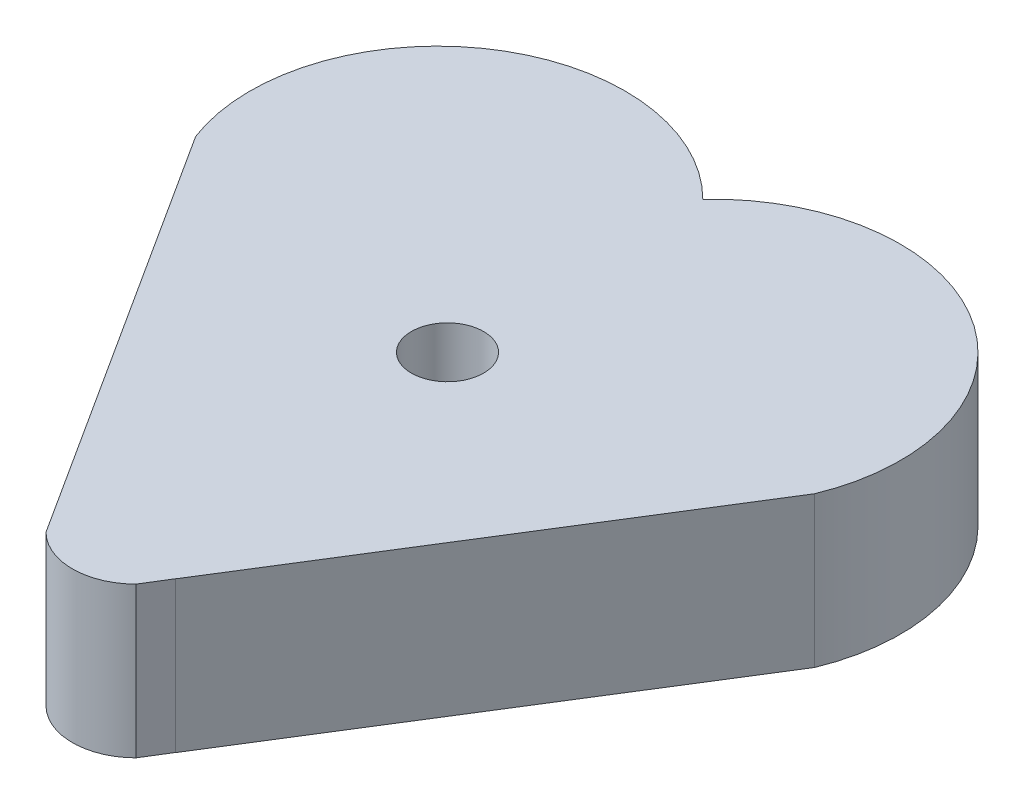
from build123d import *

# Parameters (mm, degrees)
SKETCH1_R           = 1.218989221
BOSS_EXTRUDE6_DEPTH = 5.08


with BuildPart() as part:
    # Sketch1 → Boss-Extrude6 (new body)
    with BuildSketch(Plane(origin=(0, 0, 0), x_dir=(1, 0, 0), z_dir=(0, 1, 0))):
        with BuildLine():
            ThreePointArc((-1.519001557, -12.033660962), (0, -12.662852008), (1.519001557, -12.033660962))
            Line((1.519001557, -12.033660962), (2.038136122, -11.193432272))
            ThreePointArc((2.038136122, -11.193432272), (2.034563062, -11.204068286), (2.030934498, -11.214685493))
            Line((2.030934498, -11.214685493), (10.329167319, 2.060586649))
            ThreePointArc((10.329167319, 2.060586649), (7.892426257, 9.808202336), (-0.164422722, 8.783292397))
            ThreePointArc((-0.164422722, 8.783292397), (-8.079308366, 9.623050723), (-10.561191909, 2.060586649))
            Line((-10.561191909, 2.060586649), (-9.239218773, 0))
            Line((-9.239218773, 0), (-9.150338425, -0.138539621))
            Line((-9.150338425, -0.138539621), (-2.013925132, -11.262213432))
            Line((-2.013925132, -11.262213432), (-1.519001557, -12.033660962))
        make_face()
        Circle(SKETCH1_R, mode=Mode.SUBTRACT)
    extrude(amount=BOSS_EXTRUDE6_DEPTH)


solid = part.part
